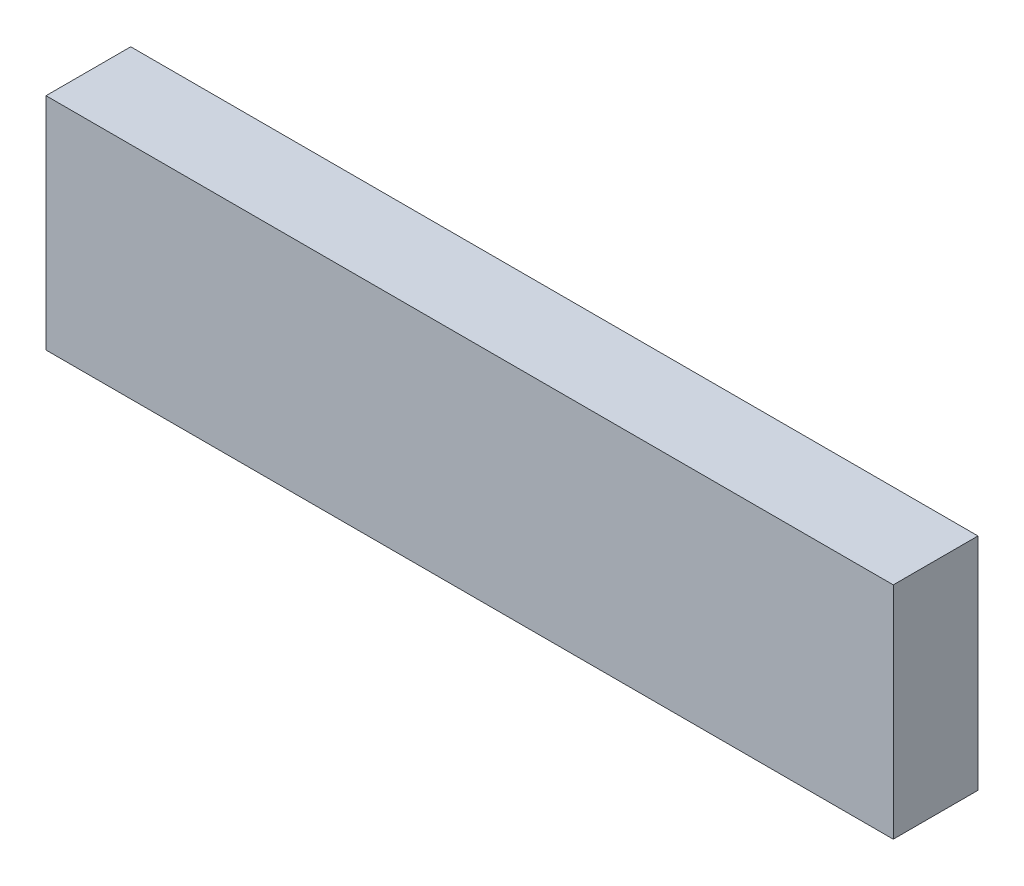
from build123d import *

# Parameters (mm, degrees)
SKETCH_1_W      = 50
SKETCH_1_H      = 13
EXTRUDE_1_DEPTH = 5


with BuildPart() as part:
    # 草圖1 → 填料-伸長1 (new body)
    with BuildSketch(Plane.XY):
        with Locations((0.90569562, 1.713709677)):
            Rectangle(SKETCH_1_W, SKETCH_1_H)
    extrude(amount=EXTRUDE_1_DEPTH)


solid = part.part
